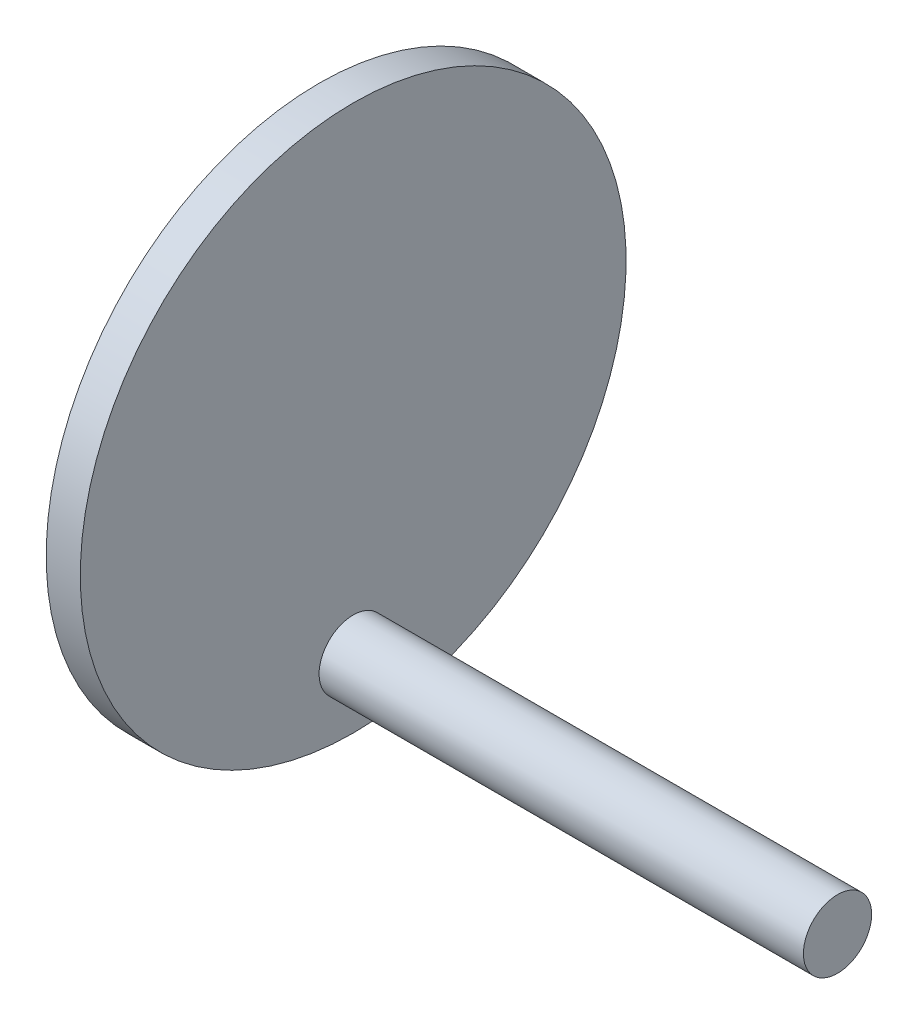
from build123d import *

# Parameters (mm, degrees)
SKETCH2_R                = 7.5
BOSS_EXTRUDE1_DEPTH      = 5
BOSS_EXTRUDE1_DEPTH_BACK = 15
SKETCH3_R                = 40
BOSS_EXTRUDE2_DEPTH      = 5
SKETCH4_R                = 5
BOSS_EXTRUDE3_DEPTH      = 70.98805519


with BuildPart() as part:
    # Sketch2 → Boss-Extrude1 (new body, two sides)
    with BuildSketch(Plane(origin=(10, 0, 0), x_dir=(0, 0, -1), z_dir=(1, 0, 0))) as boss_extrude1_sk:
        with Locations((0, 60)):
            Circle(SKETCH2_R)
    extrude(amount=BOSS_EXTRUDE1_DEPTH)
    extrude(boss_extrude1_sk.sketch, amount=-BOSS_EXTRUDE1_DEPTH_BACK)

    # Sketch3 → Boss-Extrude2 (add)
    with BuildSketch(Plane(origin=(15, 0, 0), x_dir=(0, 0, -1), z_dir=(1, 0, 0))):
        with Locations((0, 60)):
            Circle(SKETCH3_R)
    extrude(amount=BOSS_EXTRUDE2_DEPTH)

    # Sketch4 → Boss-Extrude3 (add)
    with BuildSketch(Plane(origin=(20, 0, 0), x_dir=(0, 0, -1), z_dir=(1, 0, 0))):
        with Locations((0, 30)):
            Circle(SKETCH4_R)
    extrude(amount=BOSS_EXTRUDE3_DEPTH)


solid = part.part
